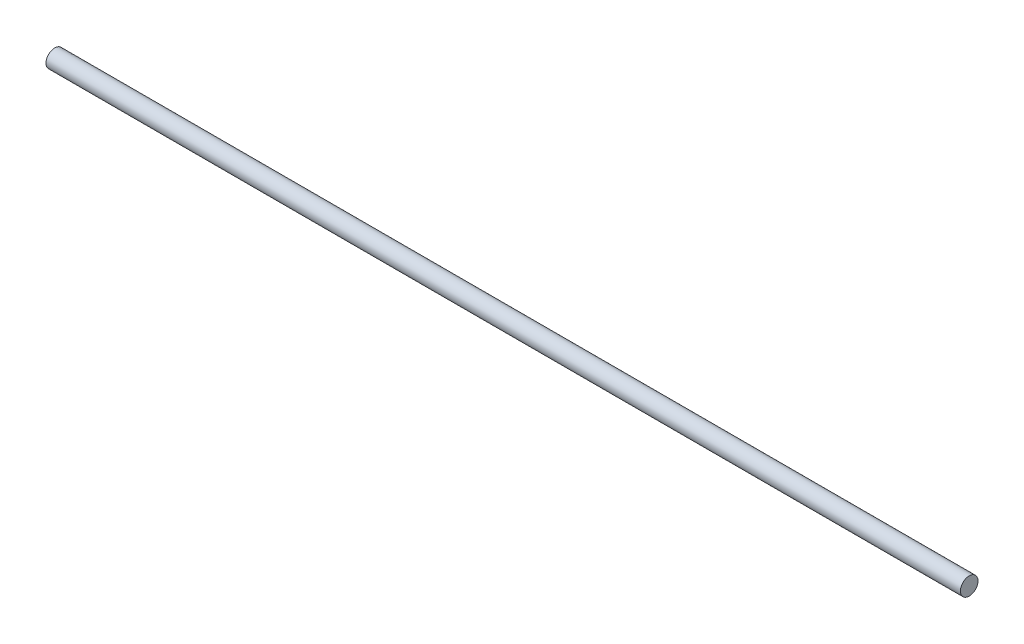
from build123d import *

# Parameters (mm, degrees)
SKETCH1_R           = 5
BOSS_EXTRUDE1_DEPTH = 260


with BuildPart() as part:
    # Sketch1 → Boss-Extrude1 (new body, symmetric)
    with BuildSketch(Plane(origin=(0, 0, 0), x_dir=(0, 0, -1), z_dir=(1, 0, 0))):
        Circle(SKETCH1_R)
    extrude(amount=BOSS_EXTRUDE1_DEPTH, both=True)


solid = part.part
